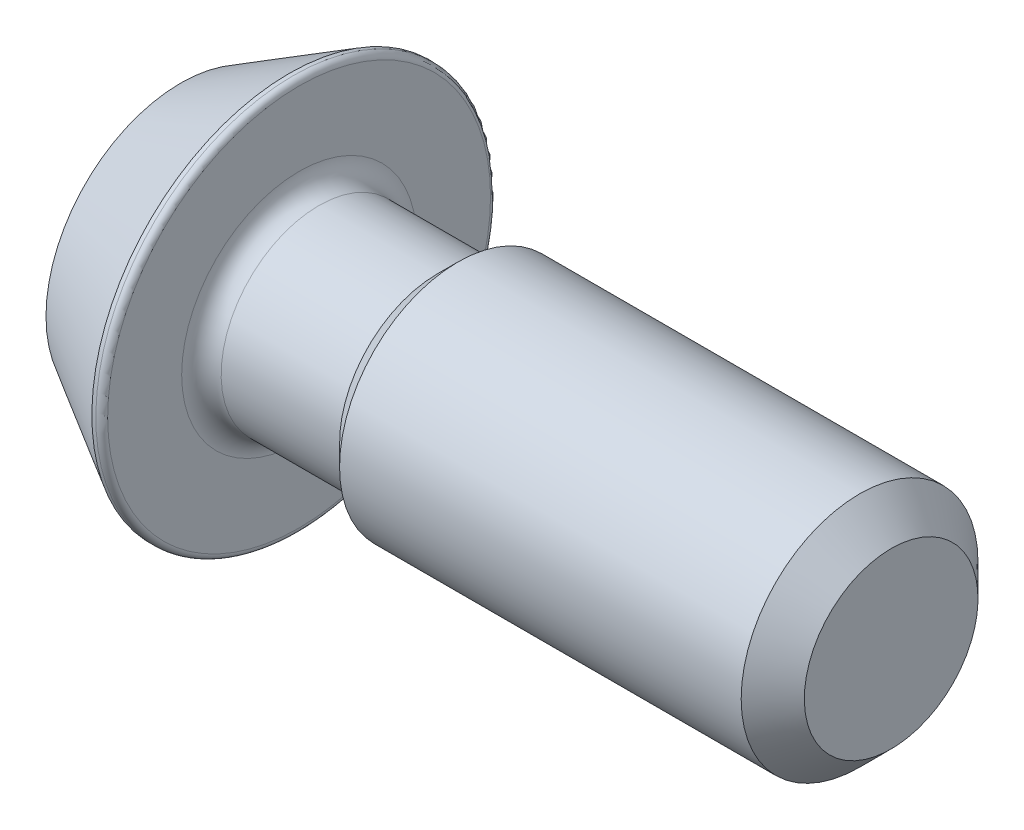
from build123d import *

# Parameters (mm, degrees)
CUT_EXTRUDE_1_DEPTH = 4
FILLET_1_R          = 0.3
CHAMFER_1_SIZE      = 1.6
FILLET_2_R          = 1


with BuildPart() as part:
    # Эскиз1 → Повернуть1 (revolve)
    with BuildSketch(Plane.XY):
        Polygon((0, 0), (0, 6.824573519), (5.5, 10), (6, 10), (6, 4.95), (13, 4.95), (14.05, 6), (36, 6), (36, 0), align=None)
    revolve(axis=Axis((36, 0, 0), (-1, 0, 0)))

    # Эскиз2 → Вырез-Вытянуть1 (cut)
    with BuildSketch(Plane.ZY):
        Polygon((1.732050808, 3), (-1.732050808, 3), (-3.464101615, 0), (-1.732050808, -3), (1.732050808, -3), (3.464101615, 0), align=None)
    extrude(amount=-CUT_EXTRUDE_1_DEPTH, mode=Mode.SUBTRACT)

    # Скругление1
    fillet_1_edges = [part.edges().sort_by_distance(p)[0] for p in [
        (6, -10, 0),
    ]]
    fillet(fillet_1_edges, radius=FILLET_1_R)

    # Фаска1
    chamfer_1_edges = [part.edges().sort_by_distance(p)[0] for p in [
        (36, -6, 0),
    ]]
    chamfer(chamfer_1_edges, length=CHAMFER_1_SIZE)

    # Скругление2
    fillet_2_edges = [part.edges().sort_by_distance(p)[0] for p in [
        (6, -4.95, 0),
    ]]
    fillet(fillet_2_edges, radius=FILLET_2_R)


solid = part.part
